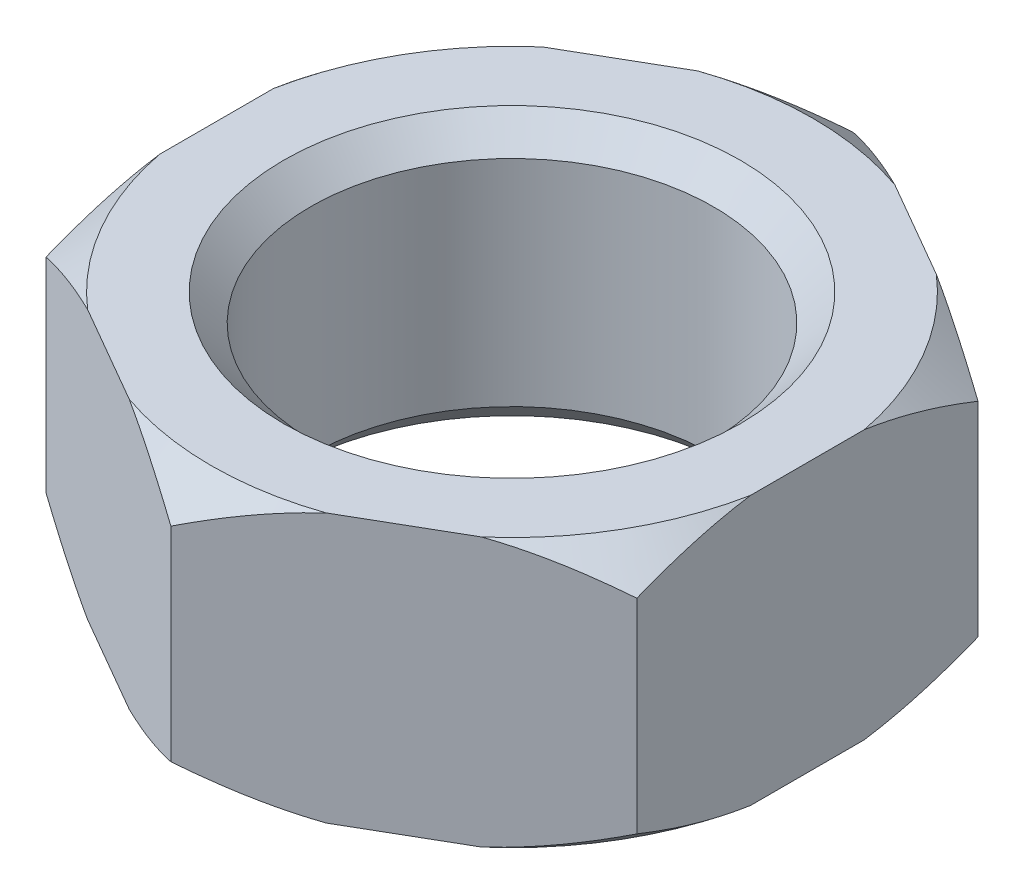
from build123d import *

# Parameters (mm, degrees)
BOSS_EXTRUDE1_DEPTH = 10
SKETCH2_R           = 7.5
CUT_EXTRUDE1_DEPTH  = 11
CHAMFER1_SIZE       = 1


with BuildPart() as part:
    # Sketch1 → Boss-Extrude1 (new body)
    with BuildSketch(Plane(origin=(0, 0, 0), x_dir=(1, 0, 0), z_dir=(0, 1, 0))):
        Polygon((0, 12.701705922), (-11, 6.350852961), (-11, -6.350852961), (0, -12.701705922), (11, -6.350852961), (11, 6.350852961), align=None)
    extrude(amount=BOSS_EXTRUDE1_DEPTH)

    # Sketch2 → Cut-Extrude1 (cut, through all)
    with BuildSketch(Plane(origin=(0, 10, 0), x_dir=(1, 0, 0), z_dir=(0, 1, 0))):
        Circle(SKETCH2_R)
    extrude(amount=-CUT_EXTRUDE1_DEPTH, mode=Mode.SUBTRACT)

    # Chamfer1
    chamfer1_edges = [part.edges().sort_by_distance(p)[0] for p in [
        (-7.5, 0, 0),
        (-7.5, 10, 0),
    ]]
    chamfer(chamfer1_edges, length=CHAMFER1_SIZE)

    # Sketch3 → Cut-Revolve1 (revolve, cut)
    with BuildSketch(Plane(origin=(0, 0, 0), x_dir=(0, 0, -1), z_dir=(1, 0, 0))):
        Polygon((-12.701705922, 10), (-11.201705922, 10), (-12.701705922, 8.8), align=None)
        Polygon((-12.701705922, 1.2), (-12.701705922, 0), (-11.201705922, 0), align=None)
    revolve(axis=Axis((0, 0, 0), (0, 1, 0)), mode=Mode.SUBTRACT)


solid = part.part
